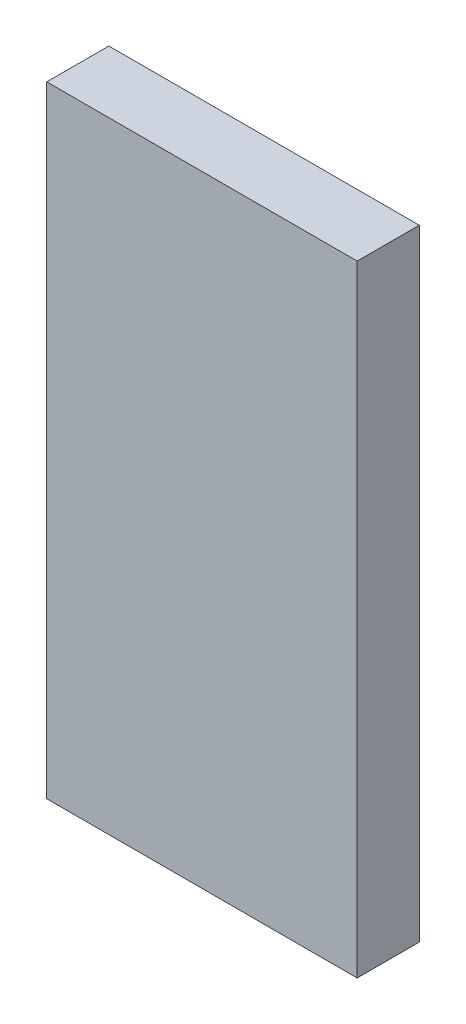
from build123d import *

# Parameters (mm, degrees)
SKETCH1_W           = 60
SKETCH1_H           = 120
BOSS_EXTRUDE1_DEPTH = 12


with BuildPart() as part:
    # Sketch1 → Boss-Extrude1 (new body)
    with BuildSketch(Plane.XY):
        Rectangle(SKETCH1_W, SKETCH1_H)
    extrude(amount=BOSS_EXTRUDE1_DEPTH)


solid = part.part
